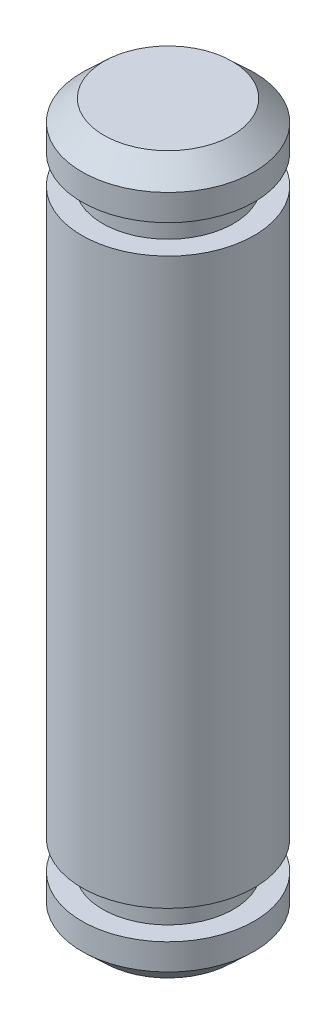
from build123d import *


with BuildPart() as part:
    # Sketch2 → Revolve4 (revolve)
    with BuildSketch(Plane.XY):
        Polygon((-1.5875, -5.207), (-1.5875, 5.207), (-1.2065, 5.207), (-1.2065, 5.7404), (-1.5875, 5.7404), (-1.5875, 6.223), (-1.182787561, 6.604), (0, 6.604), (0, -6.604), (-1.182787561, -6.604), (-1.5875, -6.223), (-1.5875, -5.7404), (-1.2065, -5.7404), (-1.2065, -5.207), align=None)
    revolve(axis=Axis((0, 0, 0), (0, 1, 0)))


solid = part.part
